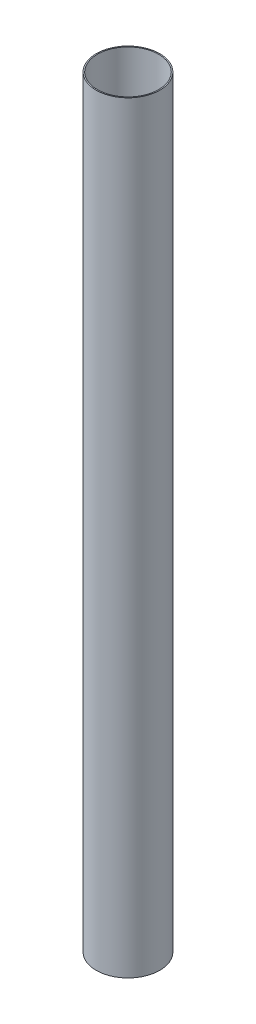
from build123d import *

# Parameters (mm, degrees)
SKETCH1_R           = 42.5
SKETCH1_R_2         = 41
BOSS_EXTRUDE1_DEPTH = 1020


with BuildPart() as part:
    # Sketch1 → Boss-Extrude1 (new body)
    with BuildSketch(Plane(origin=(0, 0, 0), x_dir=(1, 0, 0), z_dir=(0, 1, 0))):
        Circle(SKETCH1_R)
        Circle(SKETCH1_R_2, mode=Mode.SUBTRACT)
    extrude(amount=BOSS_EXTRUDE1_DEPTH)


solid = part.part
